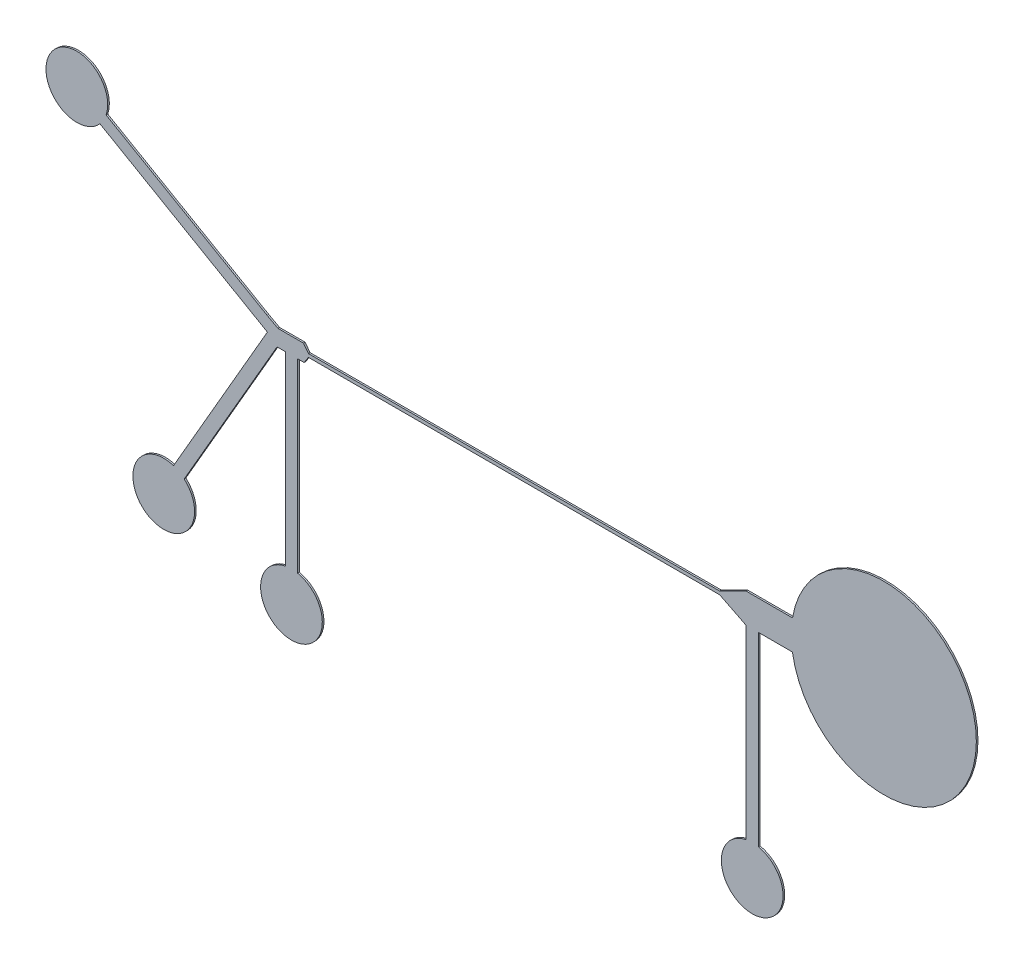
from build123d import *

# Parameters (mm, degrees)
BOSS_EXTRUDE1_DEPTH = 0.04


with BuildPart() as part:
    # Sketch1 → Boss-Extrude1 (new body)
    with BuildSketch(Plane.XY):
        with BuildLine():
            Line((-1.570502823, 0.15738204), (-1.450502823, -0.00261796))
            Line((-1.450502823, -0.00261796), (8.549497177, -0.00261796))
            Line((8.549497177, -0.00261796), (9.189497177, 0.31738204))
            Line((9.189497177, 0.31738204), (10.289497177, 0.31738204))
            Line((10.289497177, 0.31738204), (10.319580052, 0.31738204))
            ThreePointArc((10.319580052, 0.31738204), (14.789486943, -0.056102846), (10.317408472, -0.40261796))
            Line((10.317408472, -0.40261796), (10.289497177, -0.40261796))
            Line((10.289497177, -0.40261796), (9.489497177, -0.40261796))
            Line((9.489497177, -0.40261796), (9.489497177, -4.90261796))
            Line((9.489497177, -4.90261796), (9.489497177, -4.917771037))
            ThreePointArc((9.489497177, -4.917771037), (9.339497177, -6.40261796), (9.189497177, -4.917771037))
            Line((9.189497177, -4.917771037), (9.189497177, -4.90261796))
            Line((9.189497177, -4.90261796), (9.189497177, -0.40261796))
            Line((9.189497177, -0.40261796), (8.549497177, -0.08261796))
            Line((8.549497177, -0.08261796), (-1.450502823, -0.08261796))
            Line((-1.450502823, -0.08261796), (-1.553035543, -0.24261796))
            Line((-1.553035543, -0.24261796), (-1.713035543, -0.24261796))
            Line((-1.713035543, -0.24261796), (-1.713035543, -4.74261796))
            Line((-1.713035543, -4.74261796), (-1.713035543, -4.757771037))
            ThreePointArc((-1.713035543, -4.757771037), (-1.863035543, -6.24261796), (-2.013035543, -4.757771037))
            Line((-2.013035543, -4.757771037), (-2.013035543, -4.74261796))
            Line((-2.013035543, -4.74261796), (-2.013035543, -0.24261796))
            Line((-2.013035543, -0.24261796), (-2.213035543, -0.24261796))
            Line((-2.213035543, -0.24261796), (-4.46302474, -4.139738514))
            Line((-4.46302474, -4.139738514), (-4.470603357, -4.152862955))
            ThreePointArc((-4.470603357, -4.152862955), (-5.342938887, -5.363770652), (-4.730431778, -4.002851195))
            Line((-4.730431778, -4.002851195), (-4.722853967, -3.98972604))
            Line((-4.722853967, -3.98972604), (-2.447853967, -0.049310453))
            Line((-2.447853967, -0.049310453), (-6.506560021, 2.29398458))
            Line((-6.506560021, 2.29398458), (-6.519672146, 2.301573339))
            ThreePointArc((-6.519672146, 2.301573339), (-7.730602208, 3.173881322), (-6.369682971, 2.56136874))
            Line((-6.369682971, 2.56136874), (-6.356560021, 2.553792202))
            Line((-6.356560021, 2.553792202), (-2.459445704, 0.303792202))
            Line((-2.459445704, 0.303792202), (-2.191269912, 0.15738204))
            Line((-2.191269912, 0.15738204), (-1.850502745, 0.15738204))
            Line((-1.850502745, 0.15738204), (-1.570502823, 0.15738204))
        make_face()
    extrude(amount=BOSS_EXTRUDE1_DEPTH)


solid = part.part
